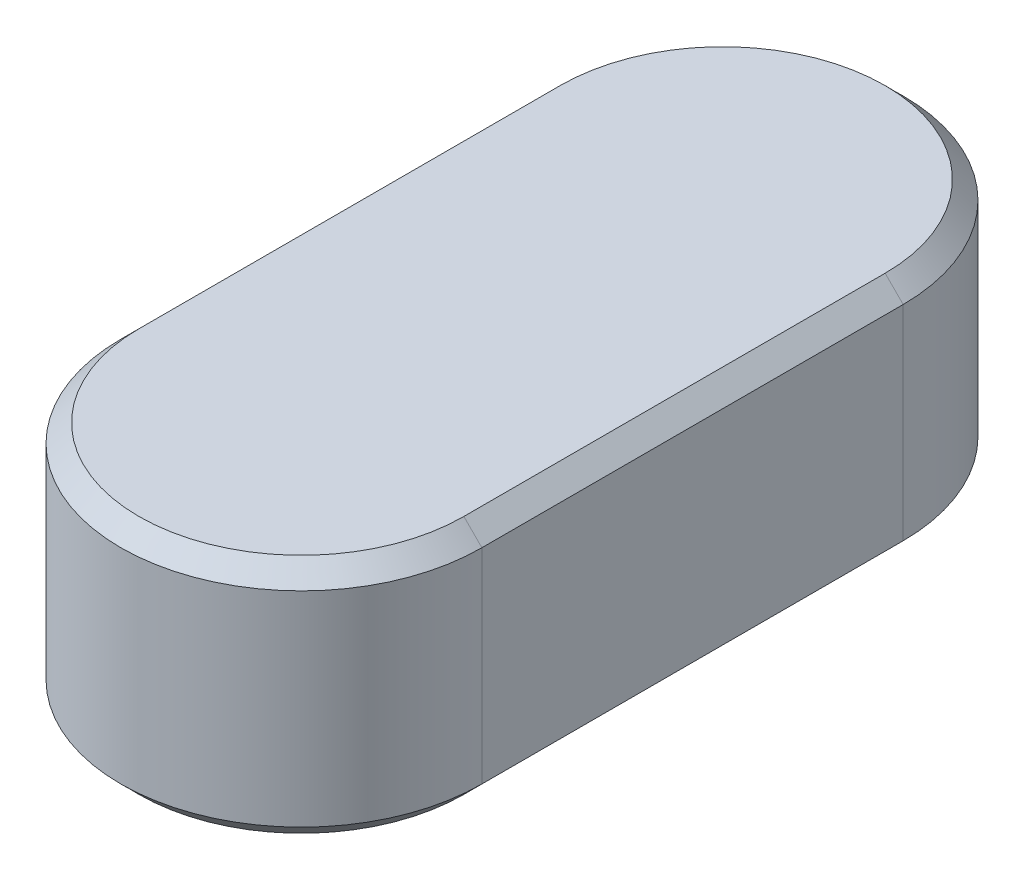
from build123d import *

# Parameters (mm, degrees)
BOSS_EXTRUDE1_DEPTH = 8
CHAMFER1_SIZE       = 0.6


with BuildPart() as part:
    # Sketch1 → Boss-Extrude1 (new body)
    with BuildSketch(Plane(origin=(0, 0, 0), x_dir=(1, 0, 0), z_dir=(0, 1, 0))):
        with BuildLine():
            Line((6, 0), (6, 14))
            ThreePointArc((6, 14), (0, 20), (-6, 14))
            Line((-6, 14), (-6, 0))
            ThreePointArc((-6, 0), (0, -6), (6, 0))
        make_face()
    extrude(amount=BOSS_EXTRUDE1_DEPTH)

    # Chamfer1
    chamfer1_edges = [part.edges().sort_by_distance(p)[0] for p in [
        (0, 8, -20),
        (-6, 8, -7),
        (0, 8, 6),
        (-6, 0, -7),
        (0, 0, -20),
        (6, 0, -7),
        (0, 0, 6),
        (6, 8, -7),
    ]]
    chamfer(chamfer1_edges, length=CHAMFER1_SIZE)


solid = part.part
